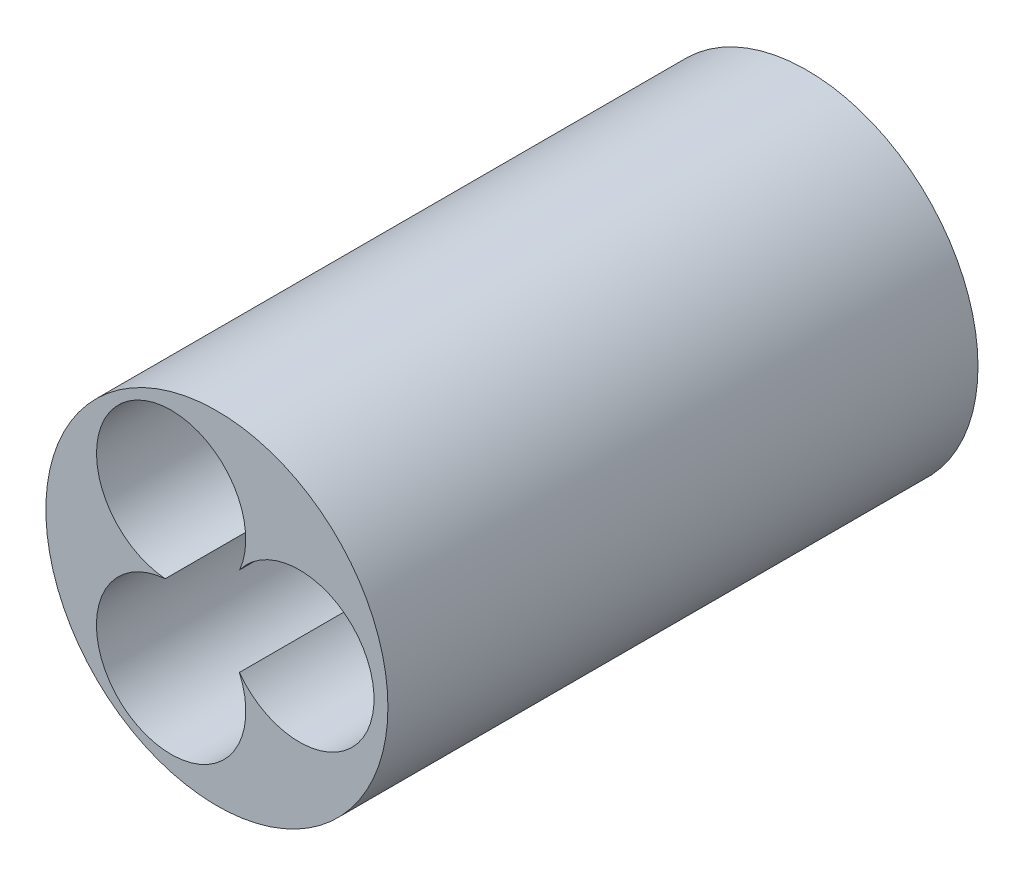
from build123d import *

# Parameters (mm, degrees)
SKETCH1_R           = 20.32
BOSS_EXTRUDE2_DEPTH = 70.1


with BuildPart() as part:
    # Sketch1 → Boss-Extrude2 (new body)
    with BuildSketch(Plane.XY):
        with Locations((5.436965925, 8.875)):
            Circle(SKETCH1_R)
        with BuildLine():
            ThreePointArc((8.106562975, 3.61237619), (8.680765272, 1.846602096), (8.875, 0))
            ThreePointArc((8.875, 0), (-6.021266525, -6.519967365), (-0.704712549, 8.84697718))
            ThreePointArc((-0.704712549, 8.84697718), (-6.013906314, 24.19612946), (8.8646, 17.683521379))
            ThreePointArc((8.8646, 17.683521379), (8.683960375, 15.903081724), (8.149403519, 14.195204385))
            ThreePointArc((8.149403519, 14.195204385), (18.04408912, 17.284412427), (24.1046, 8.875))
            ThreePointArc((24.1046, 8.875), (18.010024125, 0.454305284), (8.106562975, 3.61237619))
        make_face(mode=Mode.SUBTRACT)
    extrude(amount=BOSS_EXTRUDE2_DEPTH)


solid = part.part
